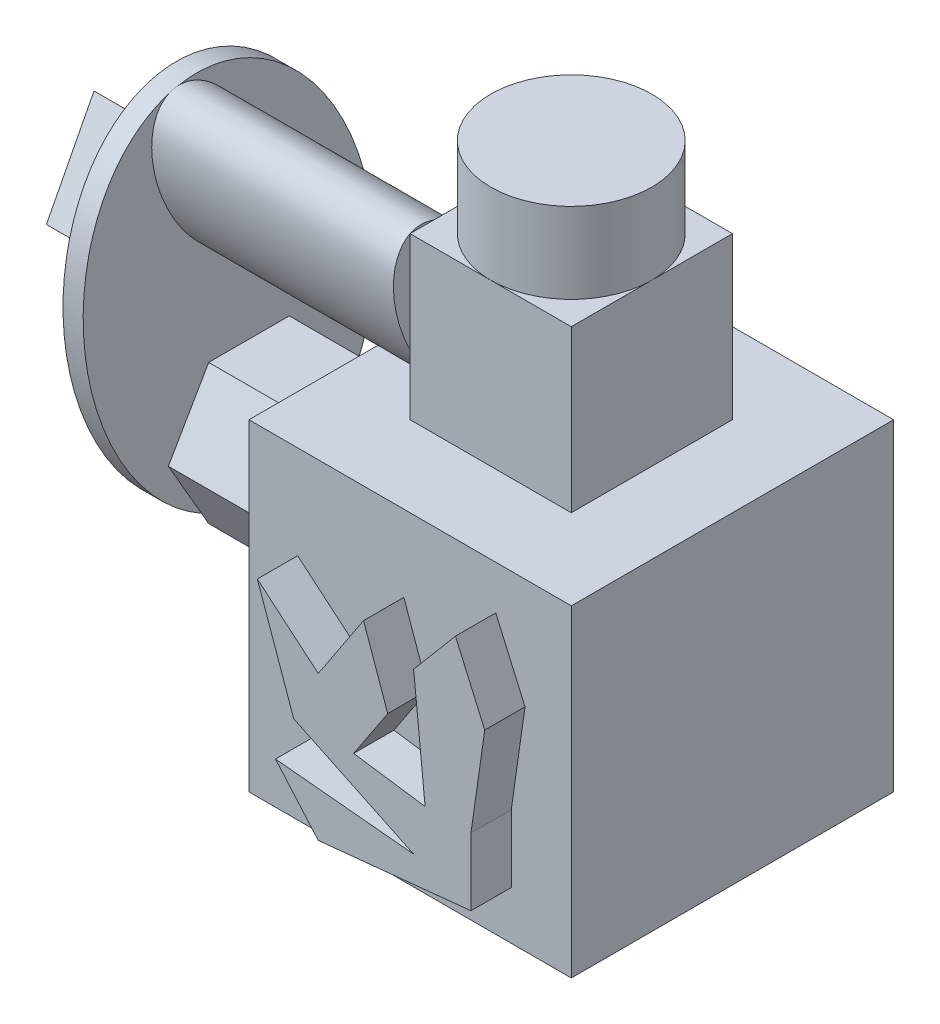
from build123d import *
from build123d.topology import SkipClean

# Parameters (mm, degrees)
SKETCH1_W           = 25.4
SKETCH1_H           = 25.4
BOSS_EXTRUDE1_DEPTH = 25.4
BOSS_EXTRUDE2_DEPTH = 12.7
SKETCH3_R           = 6.35
BOSS_EXTRUDE3_DEPTH = 6.35
SKETCH4_RX          = 7.099515829
SKETCH4_RY          = 3.549757914
BOSS_EXTRUDE4_DEPTH = 19.05
BOSS_EXTRUDE5_DEPTH = 12.7
SKETCH6_RX          = 16.167018701
SKETCH6_RY          = 10.929819125
BOSS_EXTRUDE6_DEPTH = 1.5875
BOSS_EXTRUDE7_DEPTH = 3.175
BOSS_EXTRUDE8_DEPTH = 3.175


with BuildPart() as part:
    # Sketch1 → Boss-Extrude1 (new body)
    with BuildSketch(Plane(origin=(0, 0, 0), x_dir=(1, 0, 0), z_dir=(0, 1, 0))):
        with Locations((12.7, -12.7)):
            Rectangle(SKETCH1_W, SKETCH1_H)
    extrude(amount=BOSS_EXTRUDE1_DEPTH)

    # Sketch2 → Boss-Extrude2 (add)
    with BuildSketch(Plane(origin=(0, 25.4, 0), x_dir=(1, 0, 0), z_dir=(0, 1, 0))):
        with BuildLine():
            ThreePointArc((6.35, -12.7), (8.209871939, -8.209871939), (12.7, -6.35))
            Line((12.7, -6.35), (19.05, -6.35))
            Line((19.05, -6.35), (19.05, -19.05))
            Line((19.05, -19.05), (6.35, -19.05))
            Line((6.35, -19.05), (6.35, -12.7))
        make_face()
    extrude(amount=BOSS_EXTRUDE2_DEPTH)

    # Sketch3 → Boss-Extrude3 (add)
    with SkipClean():  # keep this step's faces unmerged: merging them makes the solid invalid here
        with BuildSketch(Plane(origin=(0, 38.1, 0), x_dir=(1, 0, 0), z_dir=(0, 1, 0))):
            with Locations(Location((12.7, -12.7, 0), (0, 0, 270))):  # turned: the seam where the file's is
                Circle(SKETCH3_R)
        extrude(amount=BOSS_EXTRUDE3_DEPTH)

    # Sketch4 → Boss-Extrude4 (add)
    with SkipClean():  # keep this step's faces unmerged: merging them makes the solid invalid here
        with BuildSketch(Plane.ZY.offset(-6.35)):
            with Locations(Location((15.875, 31.75), (0, 0, 63.434948823))):
                Ellipse(SKETCH4_RX, SKETCH4_RY)
        extrude(amount=BOSS_EXTRUDE4_DEPTH)

    # Sketch5 → Boss-Extrude5 (add)
    with SkipClean():  # keep this step's faces unmerged: merging them makes the solid invalid here
        with BuildSketch(Plane.ZY):
            Polygon((9.525, 18.199261314), (8.674261314, 16.725738686), (16.725738686, 8.674261314), (19.05, 12.7), (15.875, 18.199261314), align=None)
            Polygon((16.725738686, 8.674261314), (8.674261314, 16.725738686), (6.35, 12.7), (9.525, 7.200738686), (15.875, 7.200738686), align=None)
        extrude(amount=BOSS_EXTRUDE5_DEPTH)

    # Sketch6 → Boss-Extrude6 (add)
    with SkipClean():  # keep this step's faces unmerged: merging them makes the solid invalid here
        with BuildSketch(Plane.ZY.offset(12.7)):
            with Locations(Location((14.2875, 22.650369343), (0, 0, 72.867573148))):
                Ellipse(SKETCH6_RX, SKETCH6_RY)
        extrude(amount=BOSS_EXTRUDE6_DEPTH)

    # Sketch7 → Boss-Extrude7 (add)
    with SkipClean():  # keep this step's faces unmerged: merging them makes the solid invalid here
        with BuildSketch(Plane.ZY.offset(14.2875)):
            Polygon((4.571396825, 23.629289358), (3.732973033, 22.274531466), (3.684255675, 20.682064819), (4.43829853, 19.27858957), (5.793056422, 18.440165778), (7.385523068, 18.391448421), (8.788998317, 19.145491275), (9.627422109, 20.500249167), (9.676139467, 22.092715813), (8.922096612, 23.496191063), (7.56733872, 24.334614855), (5.974872074, 24.383332212), align=None)
            Polygon((9.820093329, 15.591599788), (8.452601667, 14.002128498), (8.609564967, 11.911239943), (10.199036257, 10.54374828), (12.289924812, 10.70071158), (13.657416475, 12.290182871), (13.500453174, 14.381071426), (11.910981884, 15.748563088), align=None)
            Polygon((11.910981884, 27.703541882), (12.440145656, 25.02865315), (15.147636613, 24.705331728), (16.291794276, 27.18039683), (14.291431644, 29.033392611), align=None)
            Polygon((17.003134649, 23.496191063), (13.132029933, 22.83322326), (11.236764719, 19.393318057), (12.744512372, 15.766794232), (16.519908155, 14.684498193), (19.72000204, 16.961420933), (19.935058062, 20.882993187), align=None)
            Polygon((15.755915704, 29.615083354), (23.899741704, 29.243629963), (20.149516777, 36.482116859), align=None)
        extrude(amount=BOSS_EXTRUDE7_DEPTH)

    # Sketch8 → Boss-Extrude8 (add)
    with SkipClean():  # keep this step's faces unmerged: merging them makes the solid invalid here
        with BuildSketch(Plane.XY.offset(25.4)):
            Polygon((16.152157776, 5.413552829), (6.697554447, 9.934608829), (3.837078483, 18.037710904), (8.634948169, 13.986159866), (12.205224218, 19.382989208), (14.110358878, 13.986159866), (11.424856112, 9.926753835), (17.056057389, 9.119429964), (16.152157776, 18.037710904), (19.446911767, 21.939377241), (21.754376792, 16.684574537), (20.669790839, 9.119429964), (20.669790839, 3.810761102), (8.634948169, 2.590986831), (5.267316465, 6.465095533), align=None)
        extrude(amount=BOSS_EXTRUDE8_DEPTH)


solid = part.part
